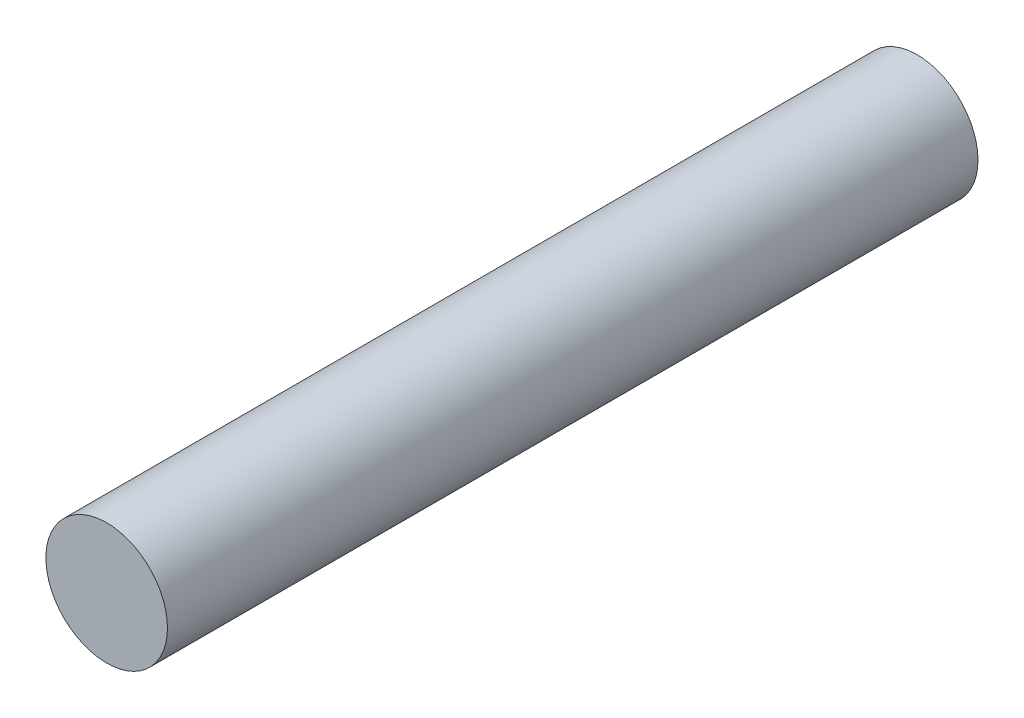
from build123d import *

# Parameters (mm, degrees)
SKETCH1_R           = 4.7625
BOSS_EXTRUDE1_DEPTH = 31.75


with BuildPart() as part:
    # Sketch1 → Boss-Extrude1 (new body, symmetric)
    with BuildSketch(Plane.XY):
        Circle(SKETCH1_R)
    extrude(amount=BOSS_EXTRUDE1_DEPTH, both=True)


solid = part.part
